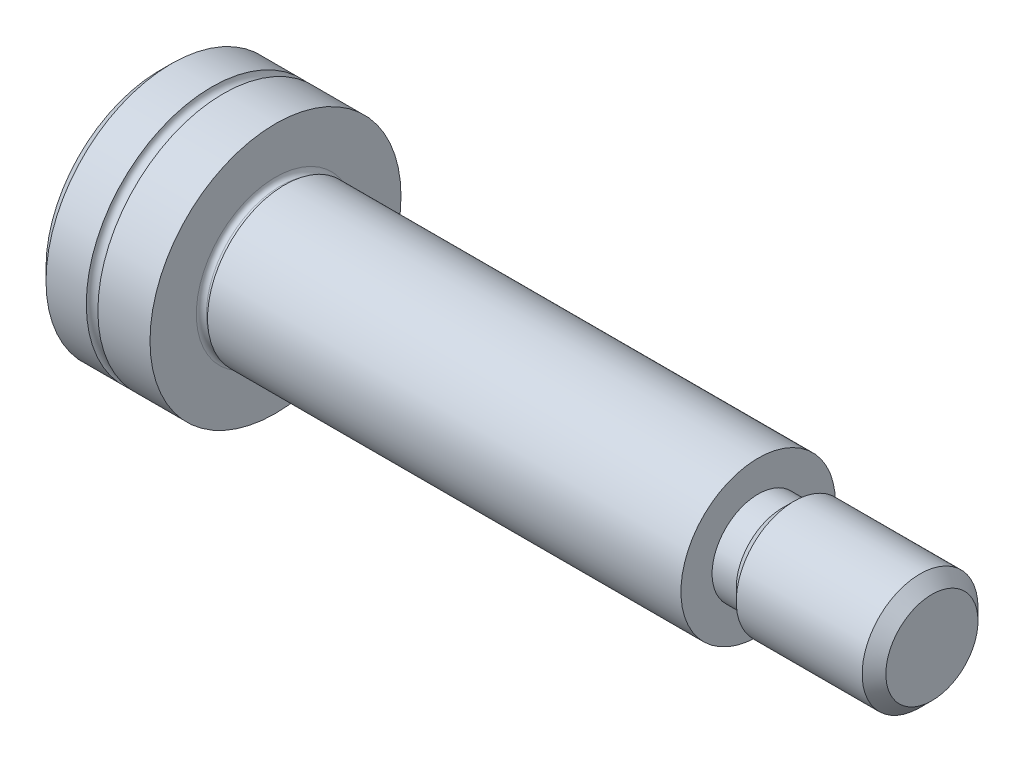
from build123d import *

# Parameters (mm, degrees)
SKETCH2_R           = 3.84
BOSS_EXTRUDE1_DEPTH = 0.387623957
SKETCH3_R           = 3.84
BOSS_EXTRUDE2_DEPTH = 0.092376043
BOSS_EXTRUDE2_TAPER = -60.000000004
SKETCH4_R           = 4
BOSS_EXTRUDE3_DEPTH = 24.52
SKETCH5_R           = 2.3865
BOSS_EXTRUDE4_DEPTH = 1.25
SKETCH6_R           = 2.3865
BOSS_EXTRUDE5_DEPTH = 0.6135
BOSS_EXTRUDE5_TAPER = -45
SKETCH7_R           = 3
BOSS_EXTRUDE6_DEPTH = 7.1365
CUT_EXTRUDE1_DEPTH  = 3
CHAMFER1_SIZE       = 0.6135
FILLET1_R           = 0.261


with BuildPart() as part:
    # Sketch1 → Revolve1 (revolve)
    with BuildSketch(Plane(origin=(0, 0, 0), x_dir=(-1, 0, 0), z_dir=(0, 0, -1))):
        with BuildLine():
            Line((0, 6.5), (0, 0))
            Line((0, 0), (6, 0))
            Line((6, 0), (6, 6.5))
            Line((6, 6.5), (3.3, 6.5))
            ThreePointArc((3.3, 6.5), (3, 6.2), (2.7, 6.5))
            Line((2.7, 6.5), (0, 6.5))
        make_face()
    revolve(axis=Axis((0, 0, 0), (-1, 0, 0)))

    # Sketch2 → Boss-Extrude1 (add)
    with BuildSketch(Plane(origin=(0, 0, 0), x_dir=(0, 0, -1), z_dir=(1, 0, 0))):
        Circle(SKETCH2_R)
    extrude(amount=BOSS_EXTRUDE1_DEPTH)

    # Sketch3 → Boss-Extrude2 (add)
    with BuildSketch(Plane(origin=(0.387623957, 0, 0), x_dir=(0, 0, -1), z_dir=(1, 0, 0))):
        Circle(SKETCH3_R)
    extrude(amount=BOSS_EXTRUDE2_DEPTH, taper=BOSS_EXTRUDE2_TAPER)

    # Sketch4 → Boss-Extrude3 (add)
    with BuildSketch(Plane(origin=(0.48, 0, 0), x_dir=(0, 0, -1), z_dir=(1, 0, 0))):
        Circle(SKETCH4_R)
    extrude(amount=BOSS_EXTRUDE3_DEPTH)

    # Sketch5 → Boss-Extrude4 (add)
    with BuildSketch(Plane(origin=(25, 0, 0), x_dir=(0, 0, -1), z_dir=(1, 0, 0))):
        Circle(SKETCH5_R)
    extrude(amount=BOSS_EXTRUDE4_DEPTH)

    # Sketch6 → Boss-Extrude5 (add)
    with BuildSketch(Plane(origin=(26.25, 0, 0), x_dir=(0, 0, -1), z_dir=(1, 0, 0))):
        Circle(SKETCH6_R)
    extrude(amount=BOSS_EXTRUDE5_DEPTH, taper=BOSS_EXTRUDE5_TAPER)

    # Sketch7 → Boss-Extrude6 (add)
    with BuildSketch(Plane(origin=(26.8635, 0, 0), x_dir=(0, 0, -1), z_dir=(1, 0, 0))):
        Circle(SKETCH7_R)
    extrude(amount=BOSS_EXTRUDE6_DEPTH)

    # Sketch8 → Cut-Extrude1 (cut)
    with BuildSketch(Plane.ZY.offset(6)):
        Polygon((2.5, -1.443375673), (2.5, 1.443375673), (0, 2.886751346), (-2.5, 1.443375673), (-2.5, -1.443375673), (0, -2.886751346), align=None)
    extrude(amount=-CUT_EXTRUDE1_DEPTH, mode=Mode.SUBTRACT)

    # Sketch9 → Cut-Revolve1 (revolve, cut)
    with BuildSketch(Plane.XY):
        Polygon((-3, 2.4), (-3, 0), (-1.614359354, 0), align=None)
    revolve(axis=Axis((-3, 0, 0), (1, 0, 0)), mode=Mode.SUBTRACT)

    # Chamfer1
    chamfer1_edges = [part.edges().sort_by_distance(p)[0] for p in [
        (34, 0, 3),
        (-6, -6.5, 0),
    ]]
    chamfer(chamfer1_edges, length=CHAMFER1_SIZE)

    # Fillet1
    fillet1_edges = [part.edges().sort_by_distance(p)[0] for p in [
        (0, 0, 3.84),
    ]]
    fillet(fillet1_edges, radius=FILLET1_R)


solid = part.part
